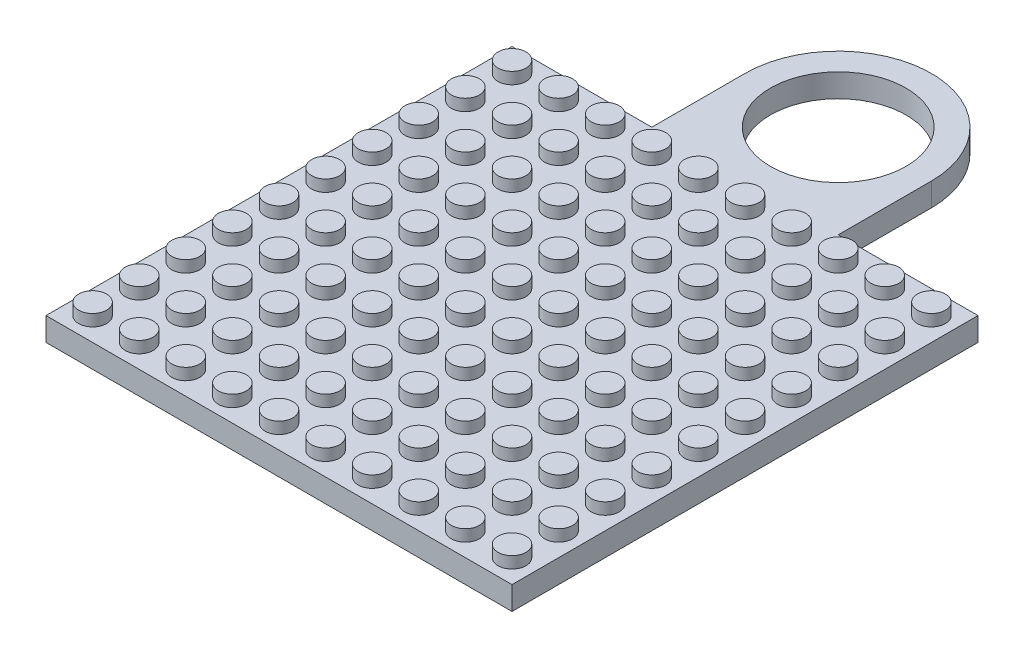
from build123d import *

# Parameters (mm, degrees)
SKETCH1_W               = 10
SKETCH1_H               = 10
PLATE_DEPTH             = 0.5
SKETCH2_R               = 0.3
ROD_DEPTH               = 0.25
LPATTERN1_COUNT         = 10
LPATTERN1_PITCH         = 1
LPATTERN1_COUNT_DIR2    = 10
LPATTERN1_PITCH_DIR2    = 1
BOSS_EXTRUDE3_DEPTH     = 0.5
SKETCH5_R               = 1.455938962
CUT_EXTRUDE1_DEPTH      = 0.5
CUT_EXTRUDE1_DEPTH_BACK = 1.5


with BuildPart() as part:
    # Sketch1 → Plate (new body)
    with BuildSketch(Plane(origin=(0, 0, 0), x_dir=(1, 0, 0), z_dir=(0, 1, 0))):
        Rectangle(SKETCH1_W, SKETCH1_H)
    extrude(amount=PLATE_DEPTH)

    # Sketch2 → Rod (add)
    with BuildSketch(Plane(origin=(0, 0.5, 0), x_dir=(1, 0, 0), z_dir=(0, 1, 0))):
        with Locations((-4.5, -4.5)):
            Circle(SKETCH2_R)
    rod = extrude(amount=ROD_DEPTH)

    # LPattern1: Rod 10 × 10
    with Locations(*[(i * LPATTERN1_PITCH, 0, -j * LPATTERN1_PITCH_DIR2) for i in range(LPATTERN1_COUNT) for j in range(LPATTERN1_COUNT_DIR2) if (i, j) != (0, 0)]):
        add(rod)

    # Sketch4 → Boss-Extrude3 (add)
    with BuildSketch(Plane(origin=(0, 0, 0), x_dir=(1, 0, 0), z_dir=(0, 1, 0))):
        with BuildLine():
            Line((-2, 7), (-2, 5))
            Line((-2, 5), (2, 5))
            Line((2, 5), (2, 7))
            ThreePointArc((2, 7), (0, 9), (-2, 7))
        make_face()
    extrude(amount=BOSS_EXTRUDE3_DEPTH)

    # Sketch5 → Cut-Extrude1 (cut, two sides)
    with BuildSketch(Plane(origin=(0, 0.5, 0), x_dir=(1, 0, 0), z_dir=(0, 1, 0))) as cut_extrude1_sk:
        with Locations((0, 7)):
            Circle(SKETCH5_R)
    extrude(amount=CUT_EXTRUDE1_DEPTH, mode=Mode.SUBTRACT)
    extrude(cut_extrude1_sk.sketch, amount=-CUT_EXTRUDE1_DEPTH_BACK, mode=Mode.SUBTRACT)


solid = part.part
